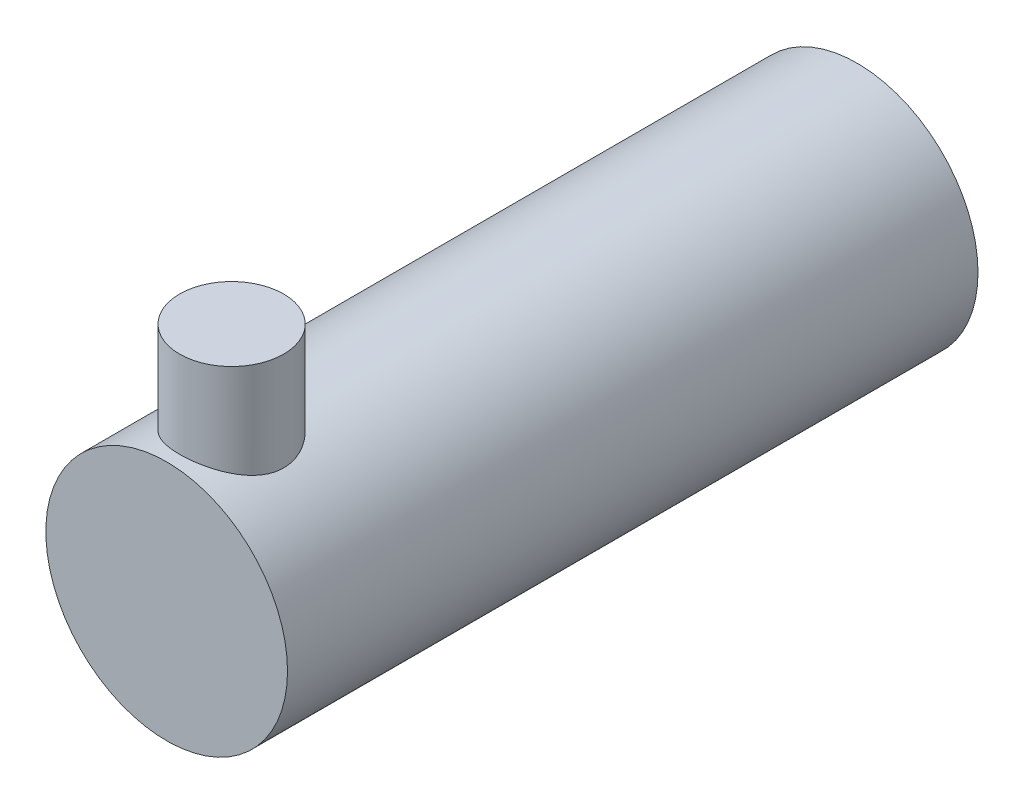
from build123d import *

# Parameters (mm, degrees)
SKETCH1_R           = 14
BOSS_EXTRUDE1_DEPTH = 80
SKETCH2_R           = 6.032002872
BOSS_EXTRUDE2_DEPTH = 13


with BuildPart() as part:
    # Sketch1 → Boss-Extrude1 (new body)
    with BuildSketch(Plane.XY):
        Circle(SKETCH1_R)
    extrude(amount=BOSS_EXTRUDE1_DEPTH)

    # Sketch2 → Boss-Extrude2 (add)
    with BuildSketch(Plane(origin=(0, 11.059444843, 0), x_dir=(1, 0, 0), z_dir=(0, 1, 0))):
        with Locations((0, -72.473685118)):
            Circle(SKETCH2_R)
    extrude(amount=BOSS_EXTRUDE2_DEPTH)


solid = part.part
